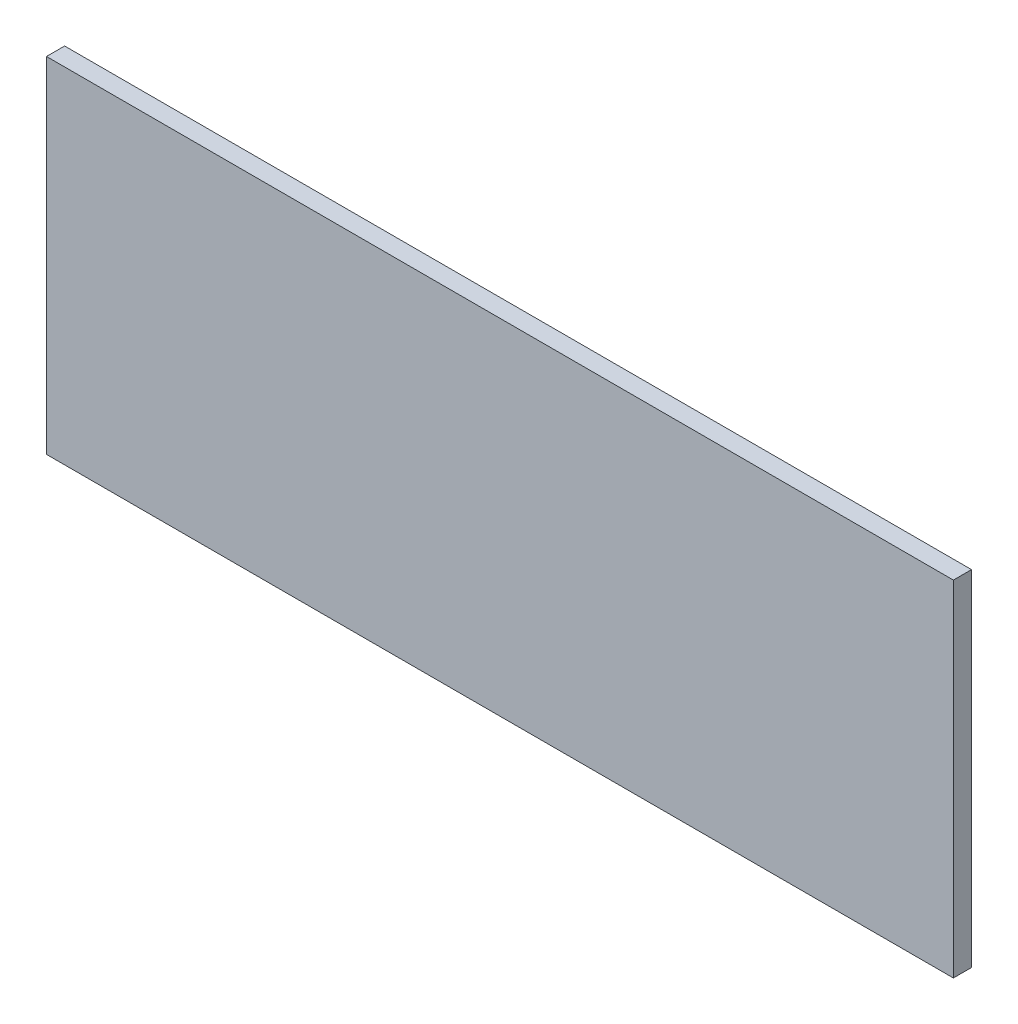
from build123d import *

# Parameters (mm, degrees)
ESQUISSE1_W        = 100
ESQUISSE1_H        = 38
BOSS_EXTRU_1_DEPTH = 2


with BuildPart() as part:
    # Esquisse1 → Boss.-Extru.1 (new body)
    with BuildSketch(Plane.XY):
        with Locations((-18.314559858, 7.158108108)):
            Rectangle(ESQUISSE1_W, ESQUISSE1_H)
    extrude(amount=BOSS_EXTRU_1_DEPTH)


solid = part.part
